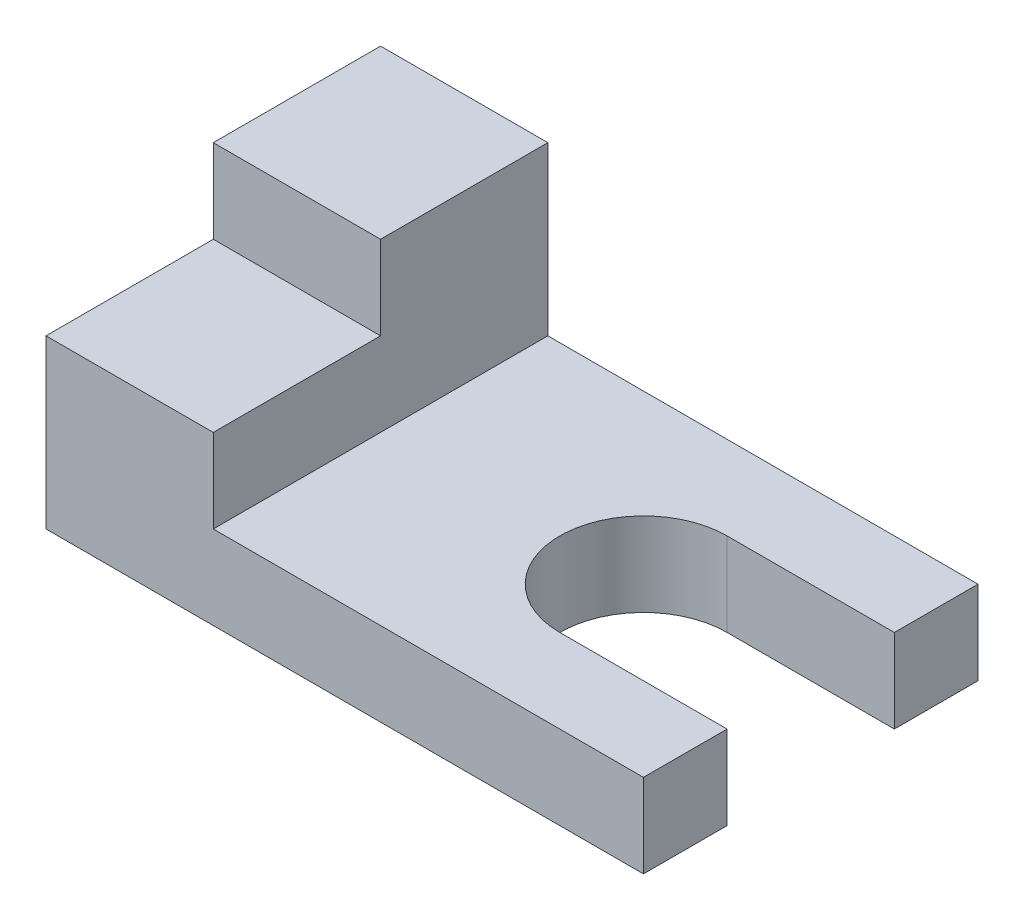
from build123d import *

# Parameters (mm, degrees)
EXTRUDE_1_DEPTH     = 28
SKETCH_2_W          = 14
SKETCH_2_H          = 14
CUT_EXTRUDE_1_DEPTH = 7
CUT_EXTRUDE_2_REACH = 23


with BuildPart() as part:
    # 스케치1 → 보스-돌출1 (new body)
    with BuildSketch(Plane.XY):
        Polygon((14, 7), (14, 21), (0, 21), (0, 0), (50, 0), (50, 7), align=None)
    extrude(amount=EXTRUDE_1_DEPTH)

    # 스케치2 → 컷-돌출1 (cut)
    with BuildSketch(Plane(origin=(0, 21, 0), x_dir=(1, 0, 0), z_dir=(0, 1, 0))):
        with Locations((7, -21)):
            Rectangle(SKETCH_2_W, SKETCH_2_H)
    extrude(amount=-CUT_EXTRUDE_1_DEPTH, mode=Mode.SUBTRACT)

    # 스케치3 → 컷-돌출2 (cut, up to next)
    with BuildSketch(Plane(origin=(0, 0, 0), x_dir=(1, 0, 0), z_dir=(0, 1, 0)), mode=Mode.PRIVATE) as cut_extrude_2_sk1:
        with BuildLine():
            Line((36, -7), (50, -7))
            Line((50, -7), (50, -21))
            Line((50, -21), (36, -21))
            ThreePointArc((36, -21), (29, -14), (36, -7))
        make_face()
    cut_extrude_2_tool1 = extrude(cut_extrude_2_sk1.sketch, amount=CUT_EXTRUDE_2_REACH, mode=Mode.PRIVATE) & part.part
    add(cut_extrude_2_tool1.solids().sort_by_distance((40.188509, 0, 14))[0], mode=Mode.SUBTRACT)


solid = part.part
